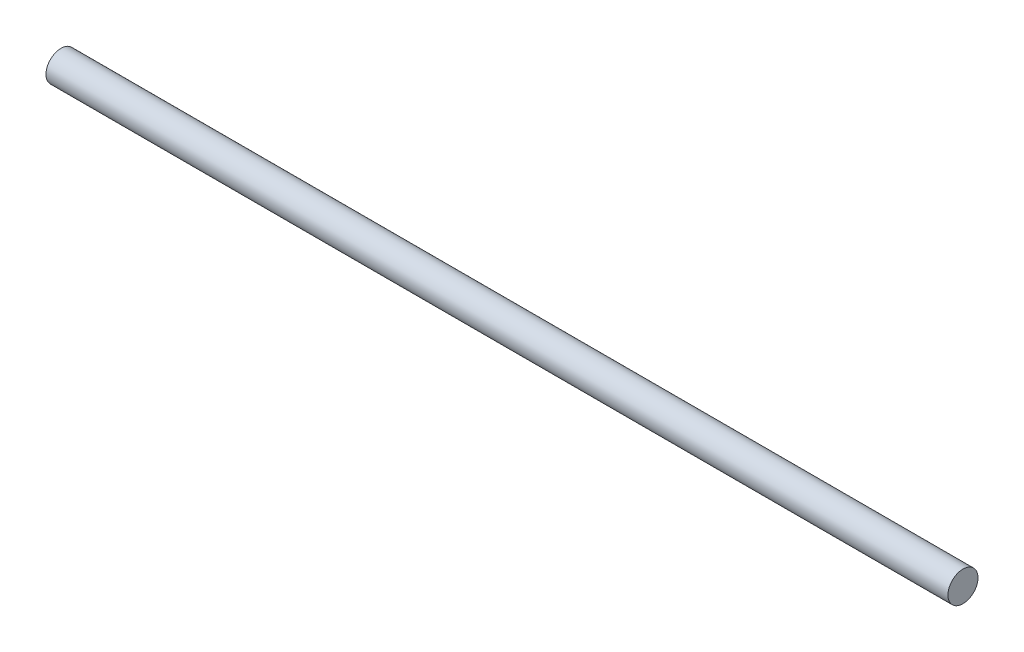
from build123d import *

# Parameters (mm, degrees)
SKETCH1_R           = 2.5
BOSS_EXTRUDE1_DEPTH = 150


with BuildPart() as part:
    # Sketch1 → Boss-Extrude1 (new body)
    with BuildSketch(Plane(origin=(0, 0, 0), x_dir=(0, 0, -1), z_dir=(1, 0, 0))):
        Circle(SKETCH1_R)
    extrude(amount=BOSS_EXTRUDE1_DEPTH)


solid = part.part
